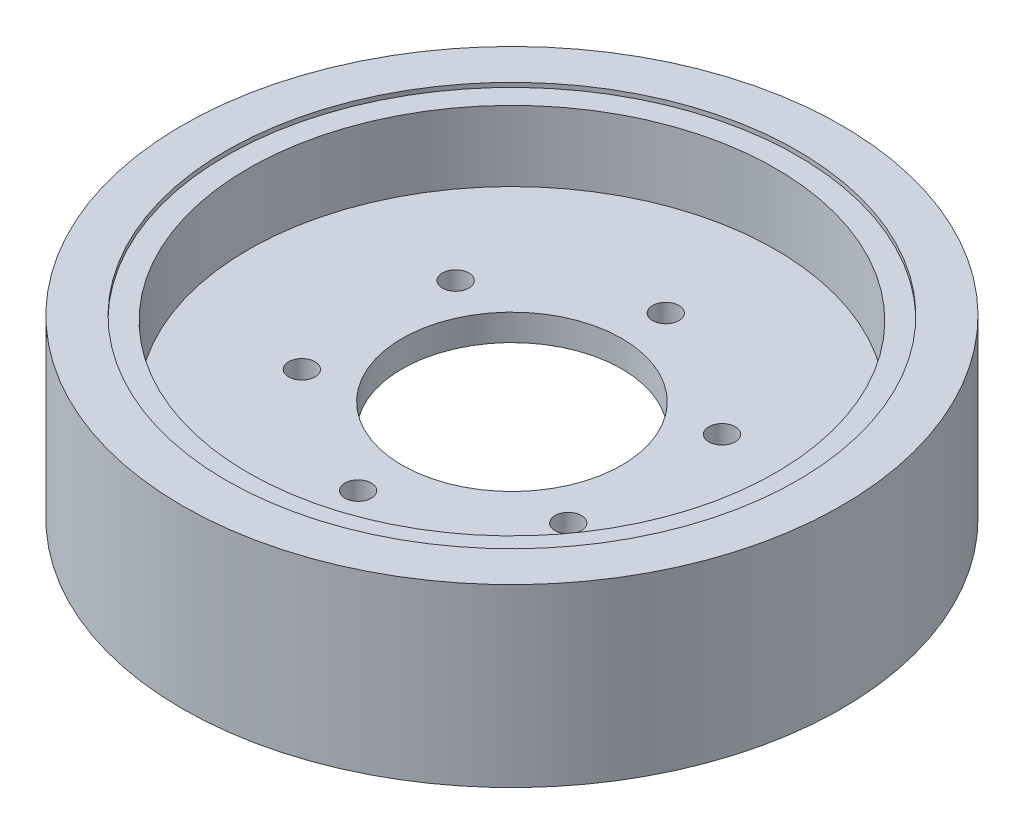
from build123d import *

# Parameters (mm, degrees)
SKETCH1_R           = 75
BOSS_EXTRUDE1_DEPTH = 40
SKETCH2_R           = 60
CUT_EXTRUDE1_DEPTH  = 17
SKETCH3_R           = 25
CUT_EXTRUDE2_DEPTH  = 24
SKETCH4_R           = 3
CUT_EXTRUDE3_DEPTH  = 24
SKETCH6_R           = 60
CUT_EXTRUDE4_DEPTH  = 17
SKETCH7_R           = 65
CUT_EXTRUDE5_DEPTH  = 1
SKETCH8_R           = 65
CUT_EXTRUDE6_DEPTH  = 1


with BuildPart() as part:
    # Sketch1 → Boss-Extrude1 (new body)
    with BuildSketch(Plane(origin=(0, 0, 0), x_dir=(1, 0, 0), z_dir=(0, 1, 0))):
        Circle(SKETCH1_R)
    extrude(amount=BOSS_EXTRUDE1_DEPTH)

    # Sketch2 → Cut-Extrude1 (cut)
    with BuildSketch(Plane(origin=(0, 40, 0), x_dir=(1, 0, 0), z_dir=(0, 1, 0))):
        Circle(SKETCH2_R)
    extrude(amount=-CUT_EXTRUDE1_DEPTH, mode=Mode.SUBTRACT)

    # Sketch3 → Cut-Extrude2 (cut, through all)
    with BuildSketch(Plane(origin=(0, 23, 0), x_dir=(1, 0, 0), z_dir=(0, 1, 0))):
        Circle(SKETCH3_R)
    extrude(amount=-CUT_EXTRUDE2_DEPTH, mode=Mode.SUBTRACT)

    # Sketch4 → Cut-Extrude3 (cut, through all)
    with BuildSketch(Plane(origin=(0, 23, 0), x_dir=(1, 0, 0), z_dir=(0, 1, 0))):
        with Locations((0, 35)):
            Circle(SKETCH4_R)
        with Locations((30.310889132, 17.5)):
            Circle(SKETCH4_R)
        with Locations((30.310889132, -17.5)):
            Circle(SKETCH4_R)
        with Locations((0, -35)):
            Circle(SKETCH4_R)
        with Locations((-30.310889132, -17.5)):
            Circle(SKETCH4_R)
        with Locations((-30.310889132, 17.5)):
            Circle(SKETCH4_R)
    extrude(amount=-CUT_EXTRUDE3_DEPTH, mode=Mode.SUBTRACT)

    # Sketch6 → Cut-Extrude4 (cut)
    with BuildSketch(Plane.XZ):
        Circle(SKETCH6_R)
    extrude(amount=-CUT_EXTRUDE4_DEPTH, mode=Mode.SUBTRACT)

    # Sketch7 → Cut-Extrude5 (cut)
    with BuildSketch(Plane.XZ):
        Circle(SKETCH7_R)
    extrude(amount=-CUT_EXTRUDE5_DEPTH, mode=Mode.SUBTRACT)

    # Sketch8 → Cut-Extrude6 (cut)
    with BuildSketch(Plane(origin=(0, 40, 0), x_dir=(1, 0, 0), z_dir=(0, 1, 0))):
        Circle(SKETCH8_R)
    extrude(amount=-CUT_EXTRUDE6_DEPTH, mode=Mode.SUBTRACT)


solid = part.part
